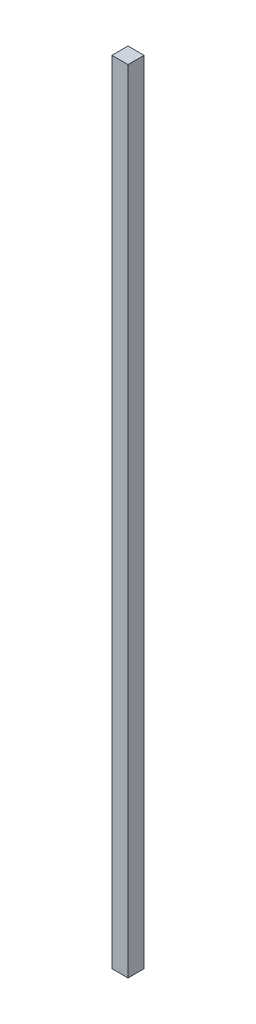
from build123d import *

# Parameters (mm, degrees)
SKETCH_1_W      = 5
SKETCH_1_H      = 5
EXTRUDE_1_DEPTH = 245.2


with BuildPart() as part:
    # Эскиз1 → Бобышка-Вытянуть1 (new body)
    with BuildSketch(Plane(origin=(0, 0, 0), x_dir=(1, 0, 0), z_dir=(0, 1, 0))):
        Rectangle(SKETCH_1_W, SKETCH_1_H)
    extrude(amount=EXTRUDE_1_DEPTH)


solid = part.part
